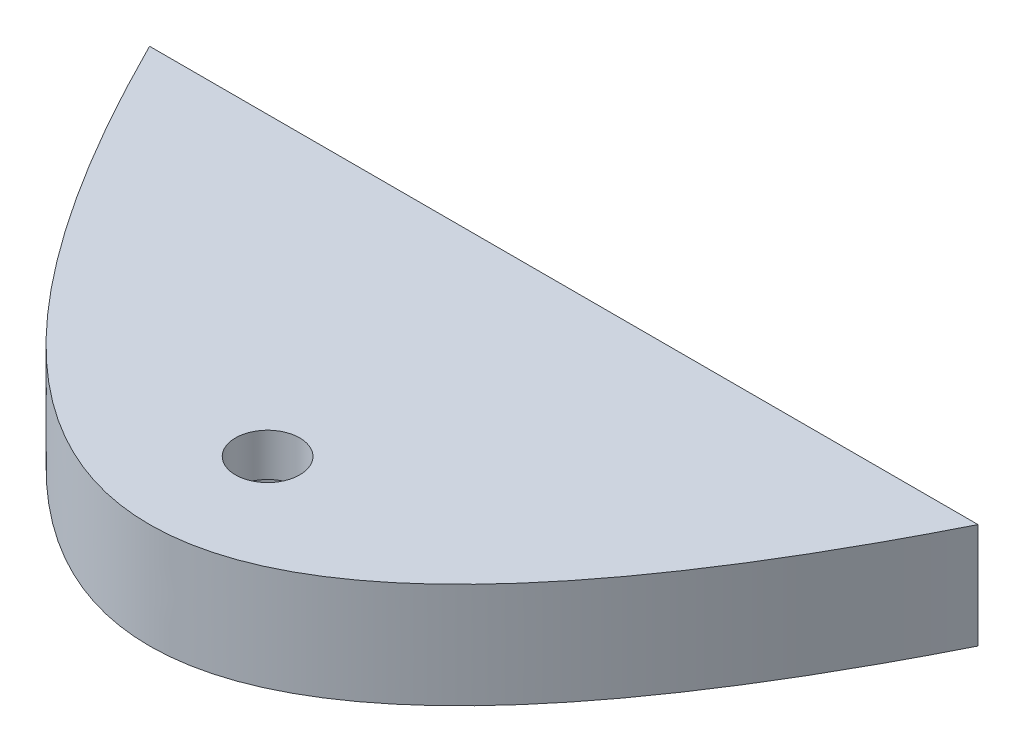
from build123d import *

# Parameters (mm, degrees)
BOSS_EXTRUDE1_DEPTH     = 300
SKETCH3_R               = 15.5
CUT_EXTRUDE1_DEPTH      = 23
CUT_EXTRUDE1_DEPTH_BACK = 23
SKETCH4_R               = 35
CUT_EXTRUDE3_DEPTH      = 300
SKETCH5_W               = 488.913893014
SKETCH5_H               = 228.614771509
SKETCH5_W_2             = 496.713117629
SKETCH5_H_2             = 107.726789986
CUT_EXTRUDE4_DEPTH      = 201.0000001


with BuildPart() as part:
    # Sketch1 → Boss-Extrude1 (new body)
    with BuildSketch(Plane(origin=(0, 0, 0), x_dir=(1, 0, 0), z_dir=(0, 1, 0))):
        with BuildLine():
            Line((-200, 1e-09), (200, 1e-09))
            add(Edge.make_bspline(
                [(-200, 1e-09), (0, -400.000000001), (200, 1e-09)],
                knots=[0.056028396, 0.056028396, 0.056028396, 0.943971604, 0.943971604, 0.943971604], degree=2))
        make_face()
    extrude(amount=BOSS_EXTRUDE1_DEPTH)

    # Sketch3 → Cut-Extrude1 (cut, two sides)
    with BuildSketch(Plane(origin=(0, 150, 0), x_dir=(1, 0, 0), z_dir=(0, 1, 0))) as cut_extrude1_sk:
        with Locations((0, -142.999999999)):
            Circle(SKETCH3_R)
    extrude(amount=CUT_EXTRUDE1_DEPTH, mode=Mode.SUBTRACT)
    extrude(cut_extrude1_sk.sketch, amount=-CUT_EXTRUDE1_DEPTH_BACK, mode=Mode.SUBTRACT)

    # Sketch4 → Cut-Extrude3 (cut)
    with BuildSketch(Plane(origin=(0, 173, 0), x_dir=(1, 0, 0), z_dir=(0, 1, 0))):
        with Locations((0, -142.999999999)):
            Circle(SKETCH4_R)
    cut_extrude3 = extrude(amount=CUT_EXTRUDE3_DEPTH, mode=Mode.SUBTRACT)

    # Mirror1: Cut-Extrude3 across plane
    add(cut_extrude3.mirror(Plane.ZX.offset(150)), mode=Mode.SUBTRACT)

    # Sketch5 → Cut-Extrude4 (cut, through all)
    with BuildSketch(Plane(origin=(0, 0, 0), x_dir=(-1, 0, 0), z_dir=(0, 0, -1))):
        with Locations((-0.974903077, 261.907385755)):
            Rectangle(SKETCH5_W, SKETCH5_H)
        with Locations((2.92470923, 42.936605007)):
            Rectangle(SKETCH5_W_2, SKETCH5_H_2)
    extrude(amount=-CUT_EXTRUDE4_DEPTH, mode=Mode.SUBTRACT)


solid = part.part
